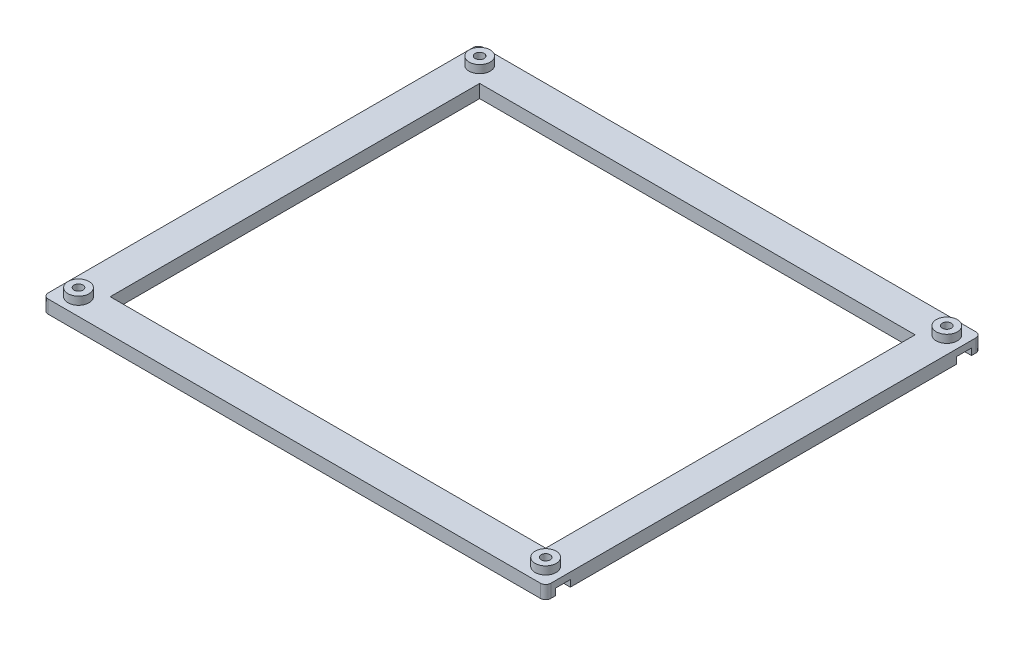
from build123d import *

# Parameters (mm, degrees)
SKETCH2_W           = 165
SKETCH2_H           = 140
BOSS_EXTRUDE1_DEPTH = 5
SKETCH2_3_R         = 1.7
BOSS_EXTRUDE2_DEPTH = 2.5
BOSS_EXTRUDE3_START = 3
SKETCH2_5_R         = 4
SKETCH2_5_R_2       = 1.7
BOSS_EXTRUDE3_DEPTH = 3
FILLET1_R           = 2


with BuildPart() as part:
    # Sketch2 → Boss-Extrude1 (new body)
    with BuildSketch(Plane(origin=(0, 0, 0), x_dir=(1, 0, 0), z_dir=(0, 1, 0))):
        Polygon((-95.5, -78.85), (-95.5, -82.5), (95, -82.5), (95, -78.85), (86.854551733, -78.85), (85.209103466, -76), (86.854551733, -73.15), (95, -73.15), (95, 73.15), (86.854551733, 73.15), (85.209103466, 76), (86.854551733, 78.85), (95, 78.85), (95, 82.5), (-95.5, 82.5), (-95.5, 78.85), (-86.854551733, 78.85), (-85.209103466, 76), (-86.854551733, 73.15), (-95.5, 73.15), (-95.5, -73.15), (-86.854551733, -73.15), (-85.209103466, -76), (-86.854551733, -78.85), align=None)
        Rectangle(SKETCH2_W, SKETCH2_H, mode=Mode.SUBTRACT)
    extrude(amount=-BOSS_EXTRUDE1_DEPTH)

    # Sketch2_3 → Boss-Extrude2 (add)
    # profile 1 of 4: a face of its own
    with BuildSketch(Plane(origin=(0, 0, 0), x_dir=(1, 0, 0), z_dir=(0, 1, 0))):
        Polygon((-95.5, -78.85), (-86.854551733, -78.85), (-85.209103466, -76), (-86.854551733, -73.15), (-95.5, -73.15), align=None)
        with Locations((-88.5, -76)):
            Circle(SKETCH2_3_R, mode=Mode.SUBTRACT)
    # profile 2 of 4: a face of its own
    with BuildSketch(Plane(origin=(0, 0, 0), x_dir=(1, 0, 0), z_dir=(0, 1, 0))):
        Polygon((95, -78.85), (95, -73.15), (86.854551733, -73.15), (85.209103466, -76), (86.854551733, -78.85), align=None)
        with Locations((88.5, -76)):
            Circle(SKETCH2_3_R, mode=Mode.SUBTRACT)
    # profile 3 of 4: a face of its own
    with BuildSketch(Plane(origin=(0, 0, 0), x_dir=(1, 0, 0), z_dir=(0, 1, 0))):
        Polygon((-95.5, 73.15), (-86.854551733, 73.15), (-85.209103466, 76), (-86.854551733, 78.85), (-95.5, 78.85), align=None)
        with Locations((-88.5, 76)):
            Circle(SKETCH2_3_R, mode=Mode.SUBTRACT)
    # profile 4 of 4: a face of its own
    with BuildSketch(Plane(origin=(0, 0, 0), x_dir=(1, 0, 0), z_dir=(0, 1, 0))):
        Polygon((95, 73.15), (95, 78.85), (86.854551733, 78.85), (85.209103466, 76), (86.854551733, 73.15), align=None)
        with Locations((88.5, 76)):
            Circle(SKETCH2_3_R, mode=Mode.SUBTRACT)
    extrude(amount=-BOSS_EXTRUDE2_DEPTH)

    # Sketch2_5 → Boss-Extrude3 (add)
    # profile 1 of 4: a face of its own
    with BuildSketch(Plane(origin=(0, 0, 0), x_dir=(1, 0, 0), z_dir=(0, 1, 0)).offset(BOSS_EXTRUDE3_START)):
        with Locations((-88.5, -76)):
            Circle(SKETCH2_5_R)
        with Locations((-88.5, -76)):
            Circle(SKETCH2_5_R_2, mode=Mode.SUBTRACT)
    # profile 2 of 4: a face of its own
    with BuildSketch(Plane(origin=(0, 0, 0), x_dir=(1, 0, 0), z_dir=(0, 1, 0)).offset(BOSS_EXTRUDE3_START)):
        with Locations((88.5, -76)):
            Circle(SKETCH2_5_R)
        with Locations((88.5, -76)):
            Circle(SKETCH2_5_R_2, mode=Mode.SUBTRACT)
    # profile 3 of 4: a face of its own
    with BuildSketch(Plane(origin=(0, 0, 0), x_dir=(1, 0, 0), z_dir=(0, 1, 0)).offset(BOSS_EXTRUDE3_START)):
        with Locations((-88.5, 76)):
            Circle(SKETCH2_5_R)
        with Locations((-88.5, 76)):
            Circle(SKETCH2_5_R_2, mode=Mode.SUBTRACT)
    # profile 4 of 4: a face of its own
    with BuildSketch(Plane(origin=(0, 0, 0), x_dir=(1, 0, 0), z_dir=(0, 1, 0)).offset(BOSS_EXTRUDE3_START)):
        with Locations((88.5, 76)):
            Circle(SKETCH2_5_R)
        with Locations((88.5, 76)):
            Circle(SKETCH2_5_R_2, mode=Mode.SUBTRACT)
    extrude(amount=-BOSS_EXTRUDE3_DEPTH)

    # Fillet1
    fillet1_edges = [part.edges().sort_by_distance(p)[0] for p in [
        (95, -2.5, -82.5),
        (-95.5, -2.5, -82.5),
        (-95.5, -2.5, 82.5),
        (95, -2.5, 82.5),
    ]]
    fillet(fillet1_edges, radius=FILLET1_R)


solid = part.part
